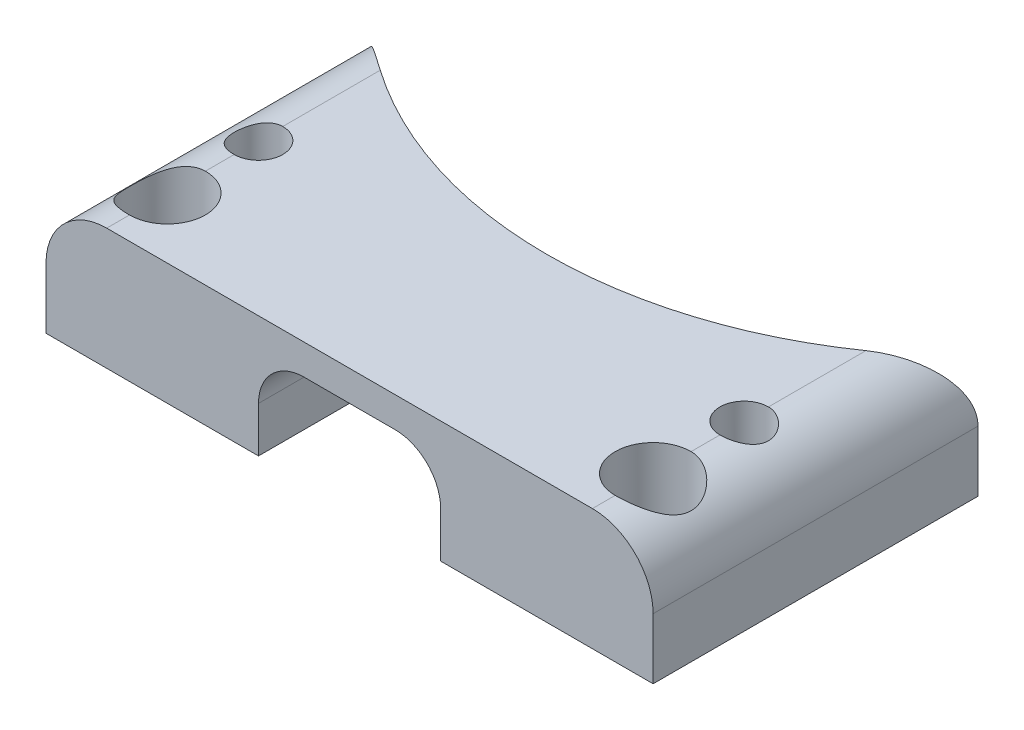
from build123d import *

# Parameters (mm, degrees)
BOSS_EXTRUDE1_DEPTH = 4
CUT_EXTRUDE1_START  = 6.5
CUT_EXTRUDE1_DEPTH  = 20.079745625
FILLET1_R           = 2
SKETCH2_R           = 0.8
SCREW_HOLES_DEPTH   = 13.579745788
SKETCH4_R           = 1.25
SCREW_HEADS_DEPTH   = 3


with BuildPart() as part:
    # Sketch5 → Boss-Extrude1 (new body)
    with BuildSketch(Plane(origin=(0, 0, 0), x_dir=(1, 0, 0), z_dir=(0, 1, 0))):
        with BuildLine():
            Line((-10, -6.5), (10, -6.5))
            Line((10, -6.5), (10, 4.202041029))
            ThreePointArc((10, 4.202041029), (0, 0), (-10, 4.202041029))
            Line((-10, 4.202041029), (-10, -6.5))
        make_face()
    extrude(amount=-BOSS_EXTRUDE1_DEPTH)

    # Sketch3 → Cut-Extrude1 (cut, through all)
    with BuildSketch(Plane.XY.offset(CUT_EXTRUDE1_START)):
        with BuildLine():
            Line((3, -4), (3, -2.5))
            ThreePointArc((3, -2.5), (2.560660172, -1.439339828), (1.5, -1))
            Line((1.5, -1), (-1.5, -1))
            ThreePointArc((-1.5, -1), (-2.560660172, -1.439339828), (-3, -2.5))
            Line((-3, -2.5), (-3, -4))
            Line((-3, -4), (0, -4))
            Line((0, -4), (3, -4))
        make_face()
    extrude(amount=-CUT_EXTRUDE1_DEPTH, mode=Mode.SUBTRACT)

    # Fillet1
    fillet1_edges = [part.edges().sort_by_distance(p)[0] for p in [
        (10, 0, 1.148979486),
        (-10, 0, 1.148979486),
    ]]
    fillet(fillet1_edges, radius=FILLET1_R)

    # Sketch2 → Screw Holes (cut, through all)
    with BuildSketch(Plane(origin=(0, 0, 0), x_dir=(1, 0, 0), z_dir=(0, 1, 0))):
        with Locations(Location((-8, -1.5, 0), (0, 0, 270))):
            Circle(SKETCH2_R)
        with Locations(Location((8, -1.5, 0), (0, 0, 270))):
            Circle(SKETCH2_R)
        with Locations(Location((8, -4.5, 0), (0, 0, 270))):
            Circle(SKETCH2_R)
        with Locations(Location((-8, -4.5, 0), (0, 0, 270))):
            Circle(SKETCH2_R)
    extrude(amount=-SCREW_HOLES_DEPTH, mode=Mode.SUBTRACT)

    # Sketch4 → Screw Heads (cut)
    with BuildSketch(Plane(origin=(0, 0, 0), x_dir=(1, 0, 0), z_dir=(0, 1, 0))):
        with Locations(Location((-8, -4.5, 0), (0, 0, 270))):
            Circle(SKETCH4_R)
        with Locations(Location((8, -4.5, 0), (0, 0, 270))):
            Circle(SKETCH4_R)
    extrude(amount=-SCREW_HEADS_DEPTH, mode=Mode.SUBTRACT)


solid = part.part
